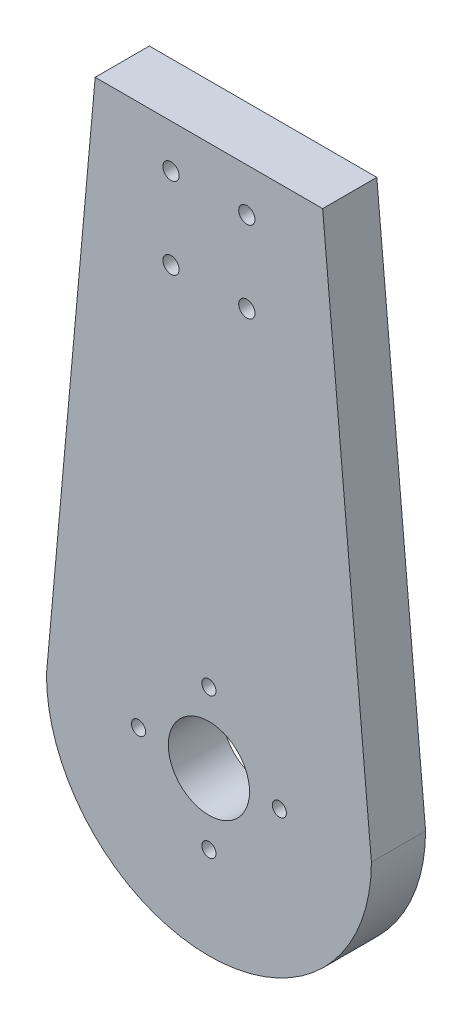
from build123d import *

# Parameters (mm, degrees)
BOSS_EXTRUDE1_DEPTH = 10
CUT_EXTRUDE1_REACH  = 12
SKETCH2_R           = 1.5
CUT_EXTRUDE2_REACH  = 12
SKETCH3_R           = 1.3
SKETCH3_R_2         = 7.5


with BuildPart() as part:
    # Sketch1 → Boss-Extrude1 (new body)
    with BuildSketch(Plane.XY):
        with BuildLine():
            Line((-21, 100), (-29.51790497, 5.356611447))
            ThreePointArc((-29.51790497, 5.356611447), (0, 30), (29.51790497, 5.356611447))
            Line((29.51790497, 5.356611447), (21, 100))
            Line((21, 100), (-21, 100))
        make_face()
        with BuildLine():
            Line((-29.51790497, 5.356611447), (-30, 0))
            ThreePointArc((-30, 0), (0, -30), (30, 0))
            Line((30, 0), (29.51790497, 5.356611447))
            ThreePointArc((29.51790497, 5.356611447), (0, 30), (-29.51790497, 5.356611447))
        make_face()
    extrude(amount=BOSS_EXTRUDE1_DEPTH)

    # Sketch2 → Cut-Extrude1 (cut, up to next)
    with BuildSketch(Plane(origin=(0, 0, 0), x_dir=(-1, 0, 0), z_dir=(0, 0, -1)), mode=Mode.PRIVATE) as cut_extrude1_sk1:
        with Locations((7, 92)):
            Circle(SKETCH2_R)
    cut_extrude1_tool1 = extrude(cut_extrude1_sk1.sketch, amount=-CUT_EXTRUDE1_REACH, mode=Mode.PRIVATE) & part.part
    add(cut_extrude1_tool1.solids().sort_by_distance((-7, 92, 0))[0], mode=Mode.SUBTRACT)
    # Sketch2 → Cut-Extrude1 (cut, up to next)
    with BuildSketch(Plane(origin=(0, 0, 0), x_dir=(-1, 0, 0), z_dir=(0, 0, -1)), mode=Mode.PRIVATE) as cut_extrude1_sk2:
        with Locations((7, 77)):
            Circle(SKETCH2_R)
    cut_extrude1_tool2 = extrude(cut_extrude1_sk2.sketch, amount=-CUT_EXTRUDE1_REACH, mode=Mode.PRIVATE) & part.part
    add(cut_extrude1_tool2.solids().sort_by_distance((-7, 77, 0))[0], mode=Mode.SUBTRACT)
    # Sketch2 → Cut-Extrude1 (cut, up to next)
    with BuildSketch(Plane(origin=(0, 0, 0), x_dir=(-1, 0, 0), z_dir=(0, 0, -1)), mode=Mode.PRIVATE) as cut_extrude1_sk3:
        with Locations((-7, 77)):
            Circle(SKETCH2_R)
    cut_extrude1_tool3 = extrude(cut_extrude1_sk3.sketch, amount=-CUT_EXTRUDE1_REACH, mode=Mode.PRIVATE) & part.part
    add(cut_extrude1_tool3.solids().sort_by_distance((7, 77, 0))[0], mode=Mode.SUBTRACT)
    # Sketch2 → Cut-Extrude1 (cut, up to next)
    with BuildSketch(Plane(origin=(0, 0, 0), x_dir=(-1, 0, 0), z_dir=(0, 0, -1)), mode=Mode.PRIVATE) as cut_extrude1_sk4:
        with Locations((-7, 92)):
            Circle(SKETCH2_R)
    cut_extrude1_tool4 = extrude(cut_extrude1_sk4.sketch, amount=-CUT_EXTRUDE1_REACH, mode=Mode.PRIVATE) & part.part
    add(cut_extrude1_tool4.solids().sort_by_distance((7, 92, 0))[0], mode=Mode.SUBTRACT)

    # Sketch3 → Cut-Extrude2 (cut, up to next)
    with BuildSketch(Plane(origin=(0, 0, 0), x_dir=(-1, 0, 0), z_dir=(0, 0, -1)), mode=Mode.PRIVATE) as cut_extrude2_sk1:
        with Locations((0, 13)):
            Circle(SKETCH3_R)
    cut_extrude2_tool1 = extrude(cut_extrude2_sk1.sketch, amount=-CUT_EXTRUDE2_REACH, mode=Mode.PRIVATE) & part.part
    add(cut_extrude2_tool1.solids().sort_by_distance((0, 13, 0))[0], mode=Mode.SUBTRACT)
    # Sketch3 → Cut-Extrude2 (cut, up to next)
    with BuildSketch(Plane(origin=(0, 0, 0), x_dir=(-1, 0, 0), z_dir=(0, 0, -1)), mode=Mode.PRIVATE) as cut_extrude2_sk2:
        with Locations((13, 0)):
            Circle(SKETCH3_R)
    cut_extrude2_tool2 = extrude(cut_extrude2_sk2.sketch, amount=-CUT_EXTRUDE2_REACH, mode=Mode.PRIVATE) & part.part
    add(cut_extrude2_tool2.solids().sort_by_distance((-13, 0, 0))[0], mode=Mode.SUBTRACT)
    # Sketch3 → Cut-Extrude2 (cut, up to next)
    with BuildSketch(Plane(origin=(0, 0, 0), x_dir=(-1, 0, 0), z_dir=(0, 0, -1)), mode=Mode.PRIVATE) as cut_extrude2_sk3:
        with Locations((0, -13)):
            Circle(SKETCH3_R)
    cut_extrude2_tool3 = extrude(cut_extrude2_sk3.sketch, amount=-CUT_EXTRUDE2_REACH, mode=Mode.PRIVATE) & part.part
    add(cut_extrude2_tool3.solids().sort_by_distance((0, -13, 0))[0], mode=Mode.SUBTRACT)
    # Sketch3 → Cut-Extrude2 (cut, up to next)
    with BuildSketch(Plane(origin=(0, 0, 0), x_dir=(-1, 0, 0), z_dir=(0, 0, -1)), mode=Mode.PRIVATE) as cut_extrude2_sk4:
        with Locations((-13, 0)):
            Circle(SKETCH3_R)
    cut_extrude2_tool4 = extrude(cut_extrude2_sk4.sketch, amount=-CUT_EXTRUDE2_REACH, mode=Mode.PRIVATE) & part.part
    add(cut_extrude2_tool4.solids().sort_by_distance((13, 0, 0))[0], mode=Mode.SUBTRACT)
    # Sketch3 → Cut-Extrude2 (cut, up to next)
    with BuildSketch(Plane(origin=(0, 0, 0), x_dir=(-1, 0, 0), z_dir=(0, 0, -1)), mode=Mode.PRIVATE) as cut_extrude2_sk5:
        Circle(SKETCH3_R_2)
    cut_extrude2_tool5 = extrude(cut_extrude2_sk5.sketch, amount=-CUT_EXTRUDE2_REACH, mode=Mode.PRIVATE) & part.part
    add(cut_extrude2_tool5.solids().sort_by_distance((0, 0, 0))[0], mode=Mode.SUBTRACT)


solid = part.part
